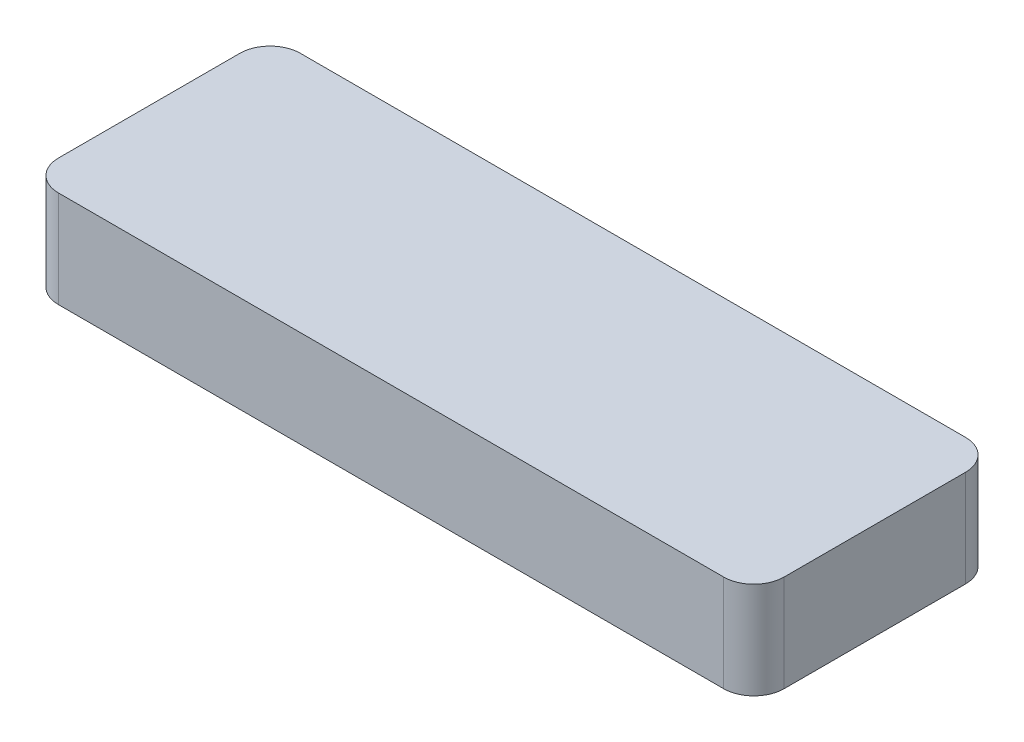
from build123d import *

# Parameters (mm, degrees)
CROQUIS1_W              = 120
CROQUIS1_H              = 40
SALIENTE_EXTRUIR1_DEPTH = 16
REDONDEO1_R             = 5


with BuildPart() as part:
    # Croquis1 → Saliente-Extruir1 (new body)
    with BuildSketch(Plane(origin=(0, 0, 0), x_dir=(1, 0, 0), z_dir=(0, 1, 0))):
        Rectangle(CROQUIS1_W, CROQUIS1_H)
    extrude(amount=SALIENTE_EXTRUIR1_DEPTH)

    # Redondeo1
    redondeo1_edges = [part.edges().sort_by_distance(p)[0] for p in [
        (60, 8, 20),
        (-60, 8, 20),
        (-60, 8, -20),
        (60, 8, -20),
    ]]
    fillet(redondeo1_edges, radius=REDONDEO1_R)


solid = part.part
